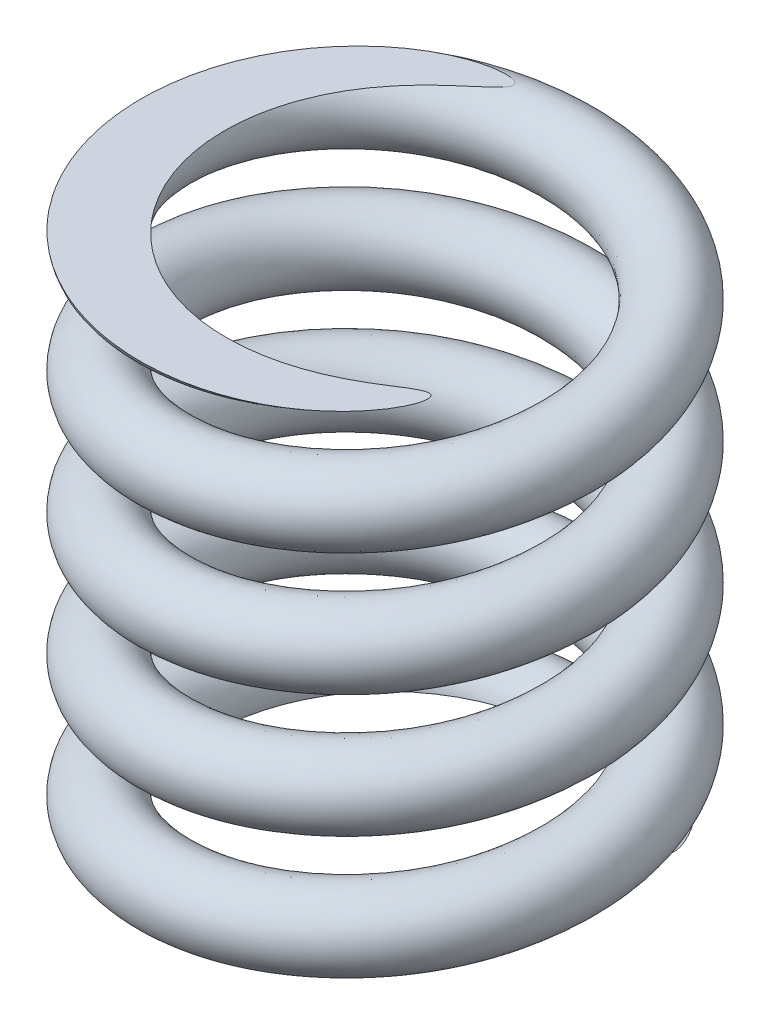
from build123d import *

# Parameters (mm, degrees)
SWEEP1_PITCH            = 1.666666667
SWEEP1_HEIGHT           = 10
SWEEP1_RADIUS           = 2.75
SWEEP1_START_ANGLE      = -90
SKETCH2_R               = 0.5
SKETCH3_W               = 8.183765968
SKETCH3_H               = 8.26155842
CUT_EXTRUDE1_DEPTH      = 1.5
CUT_EXTRUDE1_DEPTH_BACK = 1.5
CUT_EXTRUDE2_START      = -8.5
SKETCH3_3_W             = 8.183765968
SKETCH3_3_H             = 8.26155842
CUT_EXTRUDE2_DEPTH      = 11.5


with BuildPart() as part:
    # Sweep1: sweep along a helix
    with BuildLine() as sweep1_path:
        add(Helix(SWEEP1_PITCH, SWEEP1_HEIGHT, SWEEP1_RADIUS, center=(0, 0, 0), direction=(0, -1, 0), mode=Mode.PRIVATE).rotate(Axis((0, 0, 0), (0, -1, 0)), SWEEP1_START_ANGLE))
    # Sketch2 → Sweep1 (sweep)
    with BuildSketch(Plane.XY):
        with Locations((-2.75, 0)):
            Circle(SKETCH2_R)
    sweep(path=sweep1_path.line, is_frenet=True)

    # Sketch3 → Cut-Extrude1 (cut, two sides)
    with BuildSketch(Plane(origin=(0, 0, 0), x_dir=(1, 0, 0), z_dir=(0, 1, 0))) as cut_extrude1_sk:
        Rectangle(SKETCH3_W, SKETCH3_H)
    extrude(amount=CUT_EXTRUDE1_DEPTH, mode=Mode.SUBTRACT)
    extrude(cut_extrude1_sk.sketch, amount=-CUT_EXTRUDE1_DEPTH_BACK, mode=Mode.SUBTRACT)

    # Sketch3_3 → Cut-Extrude2 (cut)
    with BuildSketch(Plane(origin=(0, 0, 0), x_dir=(1, 0, 0), z_dir=(0, 1, 0)).offset(CUT_EXTRUDE2_START)):
        Rectangle(SKETCH3_3_W, SKETCH3_3_H)
    extrude(amount=-CUT_EXTRUDE2_DEPTH, mode=Mode.SUBTRACT)


solid = part.part
